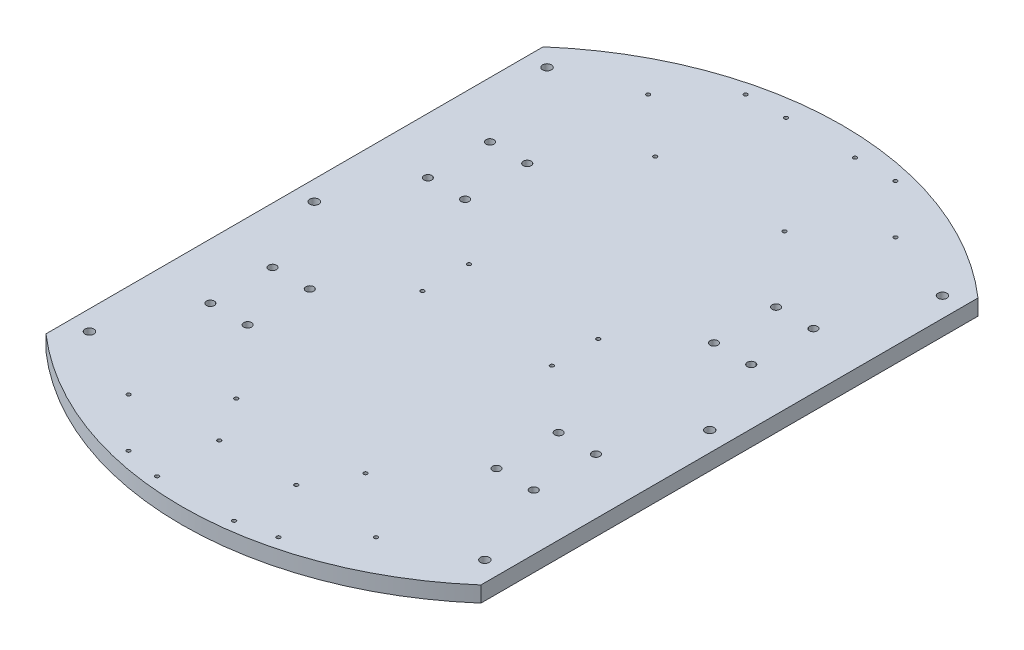
from build123d import *

# Parameters (mm, degrees)
SKETCH1_R           = 3.175
SKETCH1_R_2         = 1.5
SKETCH1_R_3         = 3.5687
BOSS_EXTRUDE1_DEPTH = 12.7


with BuildPart() as part:
    # Sketch1 → Boss-Extrude1 (new body)
    with BuildSketch(Plane(origin=(0, 0, 0), x_dir=(1, 0, 0), z_dir=(0, 1, 0))):
        with BuildLine():
            Line((175, -200), (175, 200))
            ThreePointArc((175, 200), (0, 265.753645318), (-175, 200))
            Line((-175, 200), (-175, -200))
            ThreePointArc((-175, -200), (0, -265.753645318), (175, -200))
        make_face()
        with Locations((130.12, 112.41)):
            Circle(SKETCH1_R, mode=Mode.SUBTRACT)
        with Locations((130.12, 62.41)):
            Circle(SKETCH1_R, mode=Mode.SUBTRACT)
        with Locations((100.12, 112.41)):
            Circle(SKETCH1_R, mode=Mode.SUBTRACT)
        with Locations((100.12, 62.41)):
            Circle(SKETCH1_R, mode=Mode.SUBTRACT)
        with Locations((-130.12, 62.41)):
            Circle(SKETCH1_R, mode=Mode.SUBTRACT)
        with Locations((-100.12, 62.41)):
            Circle(SKETCH1_R, mode=Mode.SUBTRACT)
        with Locations((-100.12, 112.41)):
            Circle(SKETCH1_R, mode=Mode.SUBTRACT)
        with Locations((-130.12, 112.41)):
            Circle(SKETCH1_R, mode=Mode.SUBTRACT)
        with Locations((-130.12, -62.59)):
            Circle(SKETCH1_R, mode=Mode.SUBTRACT)
        with Locations((-100.12, -62.59)):
            Circle(SKETCH1_R, mode=Mode.SUBTRACT)
        with Locations((-100.12, -112.59)):
            Circle(SKETCH1_R, mode=Mode.SUBTRACT)
        with Locations((-130.12, -112.59)):
            Circle(SKETCH1_R, mode=Mode.SUBTRACT)
        with Locations((130.12, -62.59)):
            Circle(SKETCH1_R, mode=Mode.SUBTRACT)
        with Locations((100.12, -62.59)):
            Circle(SKETCH1_R, mode=Mode.SUBTRACT)
        with Locations((100.12, -112.59)):
            Circle(SKETCH1_R, mode=Mode.SUBTRACT)
        with Locations((130.12, -112.59)):
            Circle(SKETCH1_R, mode=Mode.SUBTRACT)
        with Locations((-99.51, 209.02)):
            Circle(SKETCH1_R_2, mode=Mode.SUBTRACT)
        with Locations((-60.265573644, 248.264426356)):
            Circle(SKETCH1_R_2, mode=Mode.SUBTRACT)
        with Locations((-27.75, 248.264426356)):
            Circle(SKETCH1_R_2, mode=Mode.SUBTRACT)
        with Locations((27.75, 248.264426356)):
            Circle(SKETCH1_R_2, mode=Mode.SUBTRACT)
        with Locations((60.265573644, 248.264426356)):
            Circle(SKETCH1_R_2, mode=Mode.SUBTRACT)
        with Locations((99.51, 209.02)):
            Circle(SKETCH1_R_2, mode=Mode.SUBTRACT)
        with Locations((-60.265573644, -248.264426356)):
            Circle(SKETCH1_R_2, mode=Mode.SUBTRACT)
        with Locations((99.51, -209.02)):
            Circle(SKETCH1_R_2, mode=Mode.SUBTRACT)
        with Locations((60.265573644, -248.264426356)):
            Circle(SKETCH1_R_2, mode=Mode.SUBTRACT)
        with Locations((-99.51, -209.02)):
            Circle(SKETCH1_R_2, mode=Mode.SUBTRACT)
        with Locations((-53.36, 168.6)):
            Circle(SKETCH1_R_2, mode=Mode.SUBTRACT)
        with Locations((50.74, 168.6)):
            Circle(SKETCH1_R_2, mode=Mode.SUBTRACT)
        with Locations((-53.36, 18.7)):
            Circle(SKETCH1_R_2, mode=Mode.SUBTRACT)
        with Locations((50.74, 18.7)):
            Circle(SKETCH1_R_2, mode=Mode.SUBTRACT)
        with Locations((50.74, -18.7)):
            Circle(SKETCH1_R_2, mode=Mode.SUBTRACT)
        with Locations((-53.36, -18.7)):
            Circle(SKETCH1_R_2, mode=Mode.SUBTRACT)
        with Locations((50.74, -168.6)):
            Circle(SKETCH1_R_2, mode=Mode.SUBTRACT)
        with Locations((-53.36, -168.6)):
            Circle(SKETCH1_R_2, mode=Mode.SUBTRACT)
        with Locations((-31, -204.574478526)):
            Circle(SKETCH1_R_2, mode=Mode.SUBTRACT)
        with Locations((-31, -254.574478526)):
            Circle(SKETCH1_R_2, mode=Mode.SUBTRACT)
        with Locations((31, -254.574478526)):
            Circle(SKETCH1_R_2, mode=Mode.SUBTRACT)
        with Locations((31, -204.574478526)):
            Circle(SKETCH1_R_2, mode=Mode.SUBTRACT)
        with Locations((-159.12, 0)):
            Circle(SKETCH1_R_3, mode=Mode.SUBTRACT)
        with Locations((-159.12, -180.95)):
            Circle(SKETCH1_R_3, mode=Mode.SUBTRACT)
        with Locations((-159.12, 187.3)):
            Circle(SKETCH1_R_3, mode=Mode.SUBTRACT)
        with Locations((159.12, -180.95)):
            Circle(SKETCH1_R_3, mode=Mode.SUBTRACT)
        with Locations((159.12, 0)):
            Circle(SKETCH1_R_3, mode=Mode.SUBTRACT)
        with Locations((159.12, 187.3)):
            Circle(SKETCH1_R_3, mode=Mode.SUBTRACT)
    extrude(amount=BOSS_EXTRUDE1_DEPTH)


solid = part.part
